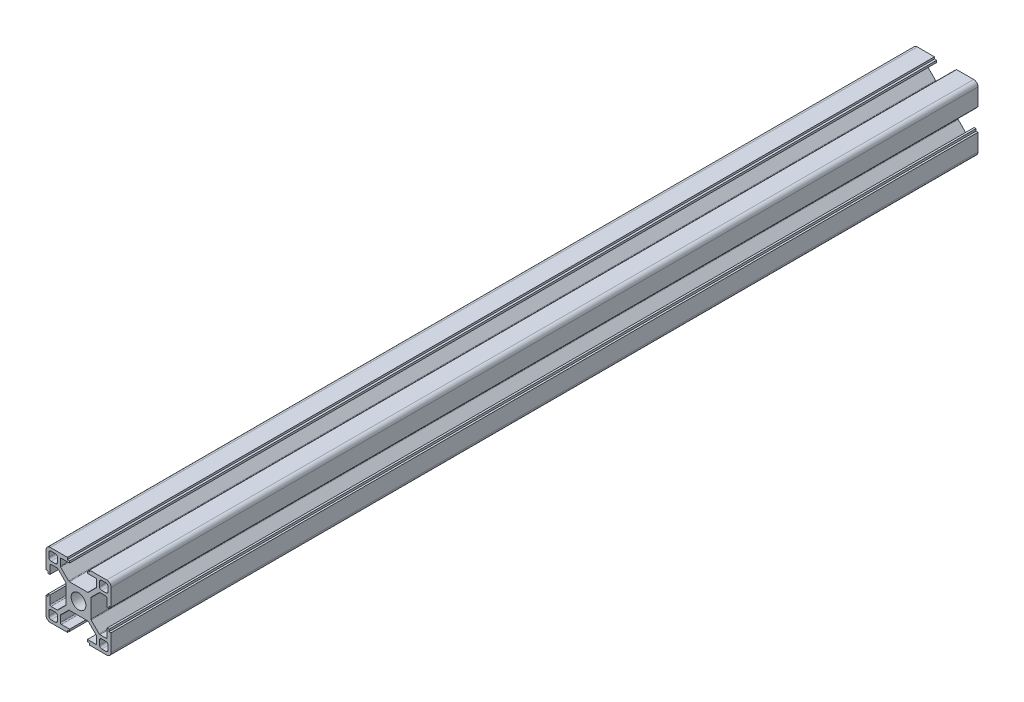
from build123d import *

# Parameters (mm, degrees)
SKETCH_1_W                       = 4
SKETCH_1_H                       = 4
EXTRUDE_1_DEPTH                  = 400
FILLET_1_R                       = 1
FILLET_2_R                       = 2
FILLET_3_R                       = 0.5
PATTERN_CIRCULAR_1_COUNT         = 4
FILLET_1_OF_PATTERN_CIRCULAR_1_R = 1
FILLET_2_OF_PATTERN_CIRCULAR_1_R = 2
FILLET_3_OF_PATTERN_CIRCULAR_1_R = 0.5
SKETCH_2_R                       = 3.4
CUT_EXTRUDE_1_DEPTH              = 401
SKETCH_3_R                       = 3.25
CUT_EXTRUDE_2_DEPTH              = 10
SKETCH_5_R                       = 3.15
CUT_EXTRUDE_3_DEPTH              = 15
SKETCH_6_R                       = 3.15
CUT_EXTRUDE_4_DEPTH              = 21.7


with BuildPart() as part:
    # 草图1 → 凸台-拉伸1 (new body)
    with BuildSketch(Plane.XY):
        Polygon((5.7, 0), (5.7, 4.427207794), (9.672792206, 8.4), (13.2, 8.4), (13.2, 4.1), (14.1, 4.1), (14.1, 5.1), (15, 5.1), (15, 15), (5.1, 15), (5.1, 14.1), (4.1, 14.1), (4.1, 13.2), (8.4, 13.2), (8.4, 9.672792206), (4.427207794, 5.7), (0, 5.7), (0, 0), align=None)
        with Locations((11.7, 11.7)):
            Rectangle(SKETCH_1_W, SKETCH_1_H, mode=Mode.SUBTRACT)
    extrude_1 = extrude(amount=EXTRUDE_1_DEPTH)

    # 圆角1
    fillet_1_edges = [part.edges().sort_by_distance(p)[0] for p in [
        (13.7, 9.7, 200),
        (13.7, 13.7, 200),
        (9.7, 13.7, 200),
        (9.7, 9.7, 200),
    ]]
    fillet(fillet_1_edges, radius=FILLET_1_R)

    # 圆角2
    fillet_2_edges = [part.edges().sort_by_distance(p)[0] for p in [
        (15, 15, 200),
    ]]
    fillet(fillet_2_edges, radius=FILLET_2_R)

    # 圆角3
    fillet_3_edges = [part.edges().sort_by_distance(p)[0] for p in [
        (4.427207794, 5.7, 200),
        (8.4, 9.672792206, 200),
        (8.4, 13.2, 200),
        (13.2, 8.4, 200),
        (9.672792206, 8.4, 200),
        (5.7, 4.427207794, 200),
    ]]
    fillet(fillet_3_edges, radius=FILLET_3_R)

    # 阵列(圆周)1: 凸台-拉伸1 ×4 about axis
    pattern_circular_1_axis = Axis((0, 0, 0), (0, 0, 1))
    for i in range(1, PATTERN_CIRCULAR_1_COUNT):
        add(extrude_1.rotate(pattern_circular_1_axis, i * 360 / PATTERN_CIRCULAR_1_COUNT))

    # 圆角1 of 阵列(圆周)1
    fillet_1_of_pattern_circular_1_edges = [part.edges().sort_by_distance(p)[0] for p in [
        (-9.7, 13.7, 200),
        (-13.7, 13.7, 200),
        (-13.7, 9.7, 200),
        (-9.7, 9.7, 200),
        (-13.7, -9.7, 200),
        (-13.7, -13.7, 200),
        (-9.7, -13.7, 200),
        (-9.7, -9.7, 200),
        (9.7, -13.7, 200),
        (13.7, -13.7, 200),
        (13.7, -9.7, 200),
        (9.7, -9.7, 200),
    ]]
    fillet(fillet_1_of_pattern_circular_1_edges, radius=FILLET_1_OF_PATTERN_CIRCULAR_1_R)

    # 圆角2 of 阵列(圆周)1
    fillet_2_of_pattern_circular_1_edges = [part.edges().sort_by_distance(p)[0] for p in [
        (-15, 15, 200),
        (-15, -15, 200),
        (15, -15, 200),
    ]]
    fillet(fillet_2_of_pattern_circular_1_edges, radius=FILLET_2_OF_PATTERN_CIRCULAR_1_R)

    # 圆角3 of 阵列(圆周)1
    fillet_3_of_pattern_circular_1_edges = [part.edges().sort_by_distance(p)[0] for p in [
        (-5.7, 4.427207794, 200),
        (-9.672792206, 8.4, 200),
        (-13.2, 8.4, 200),
        (-8.4, 13.2, 200),
        (-8.4, 9.672792206, 200),
        (-4.427207794, 5.7, 200),
        (-4.427207794, -5.7, 200),
        (-8.4, -9.672792206, 200),
        (-8.4, -13.2, 200),
        (-13.2, -8.4, 200),
        (-9.672792206, -8.4, 200),
        (-5.7, -4.427207794, 200),
        (5.7, -4.427207794, 200),
        (9.672792206, -8.4, 200),
        (13.2, -8.4, 200),
        (8.4, -13.2, 200),
        (8.4, -9.672792206, 200),
        (4.427207794, -5.7, 200),
    ]]
    fillet(fillet_3_of_pattern_circular_1_edges, radius=FILLET_3_OF_PATTERN_CIRCULAR_1_R)

    # 草图2 → 切除-拉伸1 (cut, through all)
    with BuildSketch(Plane.XY.offset(400)):
        Circle(SKETCH_2_R)
    extrude(amount=-CUT_EXTRUDE_1_DEPTH, mode=Mode.SUBTRACT)

    # 草图3 → 切除-拉伸2 (cut, symmetric)
    with BuildSketch(Plane(origin=(0, 0, 0), x_dir=(1, 0, 0), z_dir=(0, 1, 0))):
        with Locations((0, -200)):
            Circle(SKETCH_3_R)
        with Locations((0, -50)):
            Circle(SKETCH_3_R)
        with Locations((0, -350)):
            Circle(SKETCH_3_R)
    extrude(amount=CUT_EXTRUDE_2_DEPTH, both=True, mode=Mode.SUBTRACT)

    # 草图5 → 切除-拉伸3 (cut, symmetric)
    with BuildSketch(Plane(origin=(0, 0, 0), x_dir=(0, 0, -1), z_dir=(0, 1, 0))):
        with Locations((-240, 0)):
            Circle(SKETCH_5_R)
        with Locations((-160, 0)):
            Circle(SKETCH_5_R)
    extrude(amount=CUT_EXTRUDE_3_DEPTH, both=True, mode=Mode.SUBTRACT)

    # 草图6 → 切除-拉伸4 (cut, through all)
    with BuildSketch(Plane(origin=(5.7, 0, 0), x_dir=(0, 0, -1), z_dir=(1, 0, 0))):
        with Locations((-220, 0)):
            Circle(SKETCH_6_R)
        with Locations((-180, 0)):
            Circle(SKETCH_6_R)
    extrude(amount=-CUT_EXTRUDE_4_DEPTH, mode=Mode.SUBTRACT)


solid = part.part
